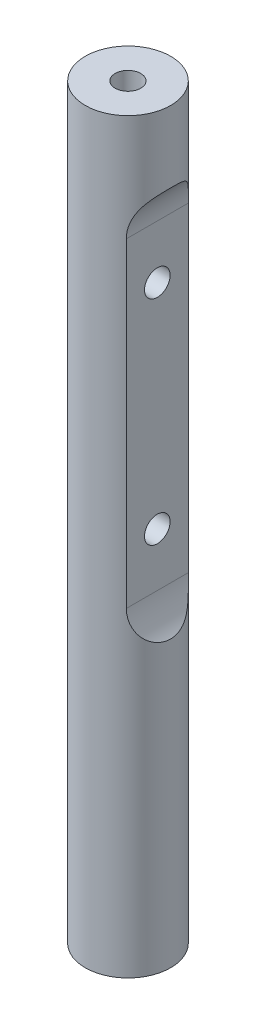
from build123d import *

# Parameters (mm, degrees)
SKETCH1_R                            = 5.08
BOSS_EXTRUDE1_DEPTH                  = 88.9
TAPPED_HOLE_FOR_4_40_HELICOIL1_D     = 3.048
TAPPED_HOLE_FOR_4_40_HELICOIL1_DEPTH = 8.128
TAPPED_HOLE_FOR_4_40_HELICOIL1_TIP   = 0.915711583
TAPPED_HOLE_FOR_4_40_HELICOIL2_D     = 3.048
TAPPED_HOLE_FOR_4_40_HELICOIL2_DEPTH = 8.128
TAPPED_HOLE_FOR_4_40_HELICOIL2_TIP   = 0.915711583
CUT_EXTRUDE1_DEPTH                   = 6.08
CUT_EXTRUDE1_DEPTH_BACK              = 6.08
TAPPED_HOLE_FOR_4_40_HELICOIL3_D     = 3.048


with BuildPart() as part:
    # Sketch1 → Boss-Extrude1 (new body)
    with BuildSketch(Plane(origin=(0, 0, 0), x_dir=(1, 0, 0), z_dir=(0, 1, 0))):
        Circle(SKETCH1_R)
    extrude(amount=BOSS_EXTRUDE1_DEPTH)

    # Tapped Hole for #4-40 Helicoil1
    with Locations(Plane(origin=(0, 88.9, 0), x_dir=(1, 0, 0), z_dir=(0, 1, 0))):
        with Locations((0, 0)):
            Hole(TAPPED_HOLE_FOR_4_40_HELICOIL1_D / 2, depth=TAPPED_HOLE_FOR_4_40_HELICOIL1_DEPTH)
            with Locations((0, 0, -(TAPPED_HOLE_FOR_4_40_HELICOIL1_DEPTH + TAPPED_HOLE_FOR_4_40_HELICOIL1_TIP / 2))):  # 118° drill point
                Cone(0, TAPPED_HOLE_FOR_4_40_HELICOIL1_D / 2, TAPPED_HOLE_FOR_4_40_HELICOIL1_TIP, mode=Mode.SUBTRACT)

    # Tapped Hole for #4-40 Helicoil2
    with Locations(Plane(origin=(0, 0, 0), x_dir=(-1, 0, 0), z_dir=(0, -1, 0))):
        with Locations((0, 0)):
            Hole(TAPPED_HOLE_FOR_4_40_HELICOIL2_D / 2, depth=TAPPED_HOLE_FOR_4_40_HELICOIL2_DEPTH)
            with Locations((0, 0, -(TAPPED_HOLE_FOR_4_40_HELICOIL2_DEPTH + TAPPED_HOLE_FOR_4_40_HELICOIL2_TIP / 2))):  # 118° drill point
                Cone(0, TAPPED_HOLE_FOR_4_40_HELICOIL2_D / 2, TAPPED_HOLE_FOR_4_40_HELICOIL2_TIP, mode=Mode.SUBTRACT)

    # Sketch8 → Cut-Extrude1 (cut, two sides)
    with BuildSketch(Plane.XY) as cut_extrude1_sk:
        with BuildLine():
            ThreePointArc((5.08, 80.400130206), (3.902618898, 78.44506403), (3.4925, 76.2))
            Line((3.4925, 76.2), (3.4925, 38.1))
            ThreePointArc((3.4925, 38.1), (3.902618898, 35.85493597), (5.08, 33.899869794))
            Line((5.08, 33.899869794), (5.08, 80.400130206))
        make_face()
    extrude(amount=CUT_EXTRUDE1_DEPTH, mode=Mode.SUBTRACT)
    extrude(cut_extrude1_sk.sketch, amount=-CUT_EXTRUDE1_DEPTH_BACK, mode=Mode.SUBTRACT)

    # Tapped Hole for #4-40 Helicoil3 (through all)
    with Locations(Plane(origin=(3.4925, 0, 0), x_dir=(0, 0, -1), z_dir=(1, 0, 0))):
        with Locations((0, 69.85), (0, 44.45)):
            Hole(TAPPED_HOLE_FOR_4_40_HELICOIL3_D / 2)


solid = part.part
